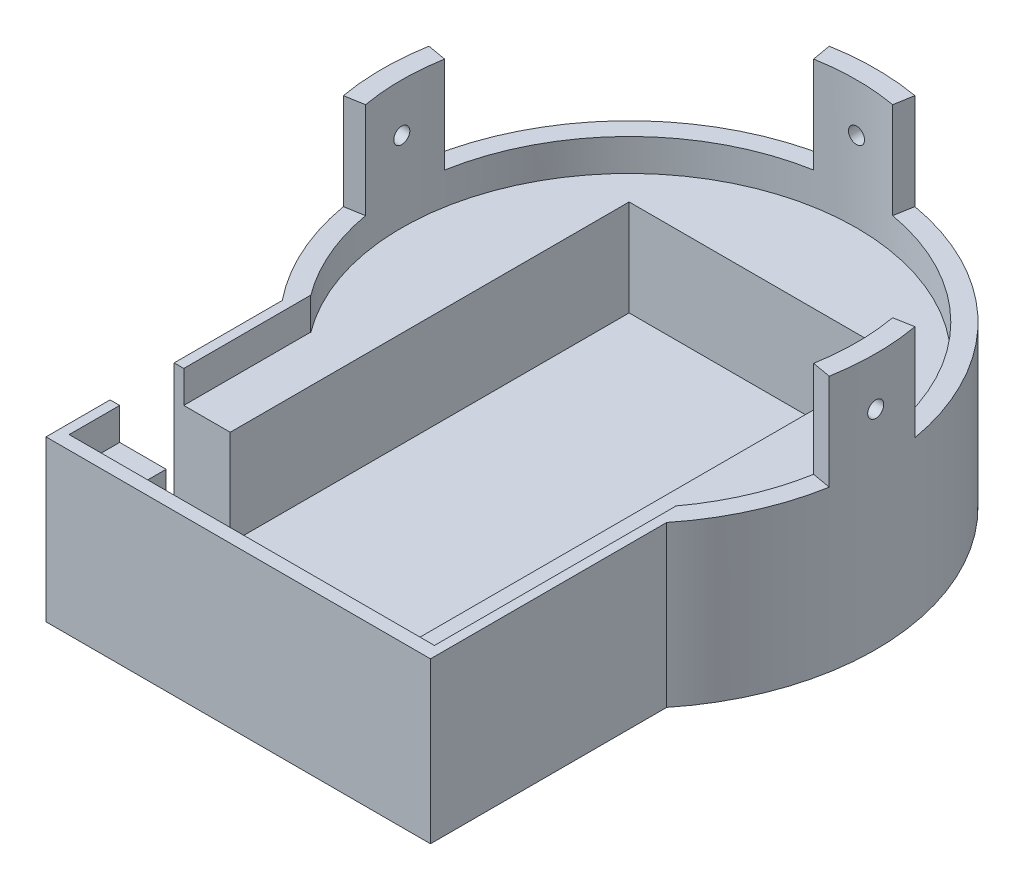
from build123d import *

# Parameters (mm, degrees)
EXTRUDE_1_DEPTH                 = 50
SKETCH_2_W                      = 85
SKETCH_2_H                      = 85
CUT_EXTRUDE_1_DEPTH             = 40
SKETCH_3_R                      = 71
CUT_EXTRUDE_2_DEPTH             = 10
EXTRUDE_2_DEPTH                 = 30
PATTERN_CIRCULAR_1_COUNT        = 4
PATTERN_CIRCULAR_1_COPY_1_DEPTH = 30
PATTERN_CIRCULAR_1_COPY_2_DEPTH = 30
SKETCH_8_R                      = 2.5
CUT_EXTRUDE_3_DEPTH             = 30
PATTERN_CIRCULAR_2_COUNT        = 4
CUT_EXTRUDE_4_DEPTH             = 10
SKETCH_10_W                     = 85
SKETCH_10_H                     = 75.258890594
CUT_EXTRUDE_6_DEPTH             = 30
SKETCH_11_W                     = 114
SKETCH_11_H                     = 4.24
EXTRUDE_3_DEPTH                 = 10
SKETCH_12_W                     = 40
SKETCH_12_H                     = 20
CUT_EXTRUDE_7_DEPTH             = 40


with BuildPart() as part:
    # Эскиз1 → Бобышка-Вытянуть1 (new body)
    with BuildSketch(Plane(origin=(0, 0, 0), x_dir=(1, 0, 0), z_dir=(0, 1, 0))):
        with BuildLine():
            Line((-60, -74.613885), (-60, -48.259714048))
            ThreePointArc((-60, -48.259714048), (0, 77), (60, -48.259714048))
            Line((60, -48.259714048), (60, -74.613885))
            Line((60, -74.613885), (60, -122))
            Line((60, -122), (-60, -122))
            Line((-60, -122), (-60, -74.613885))
        make_face()
    extrude(amount=EXTRUDE_1_DEPTH)

    # Эскиз2 → Вырез-Вытянуть1 (cut)
    with BuildSketch(Plane(origin=(0, 50, 0), x_dir=(1, 0, 0), z_dir=(0, 1, 0))):
        Rectangle(SKETCH_2_W, SKETCH_2_H)
    extrude(amount=-CUT_EXTRUDE_1_DEPTH, mode=Mode.SUBTRACT)

    # Эскиз3 → Вырез-Вытянуть2 (cut)
    with BuildSketch(Plane(origin=(0, 50, 0), x_dir=(1, 0, 0), z_dir=(0, 1, 0))):
        Circle(SKETCH_3_R)
    extrude(amount=-CUT_EXTRUDE_2_DEPTH, mode=Mode.SUBTRACT)

    # Эскиз4 → Бобышка-Вытянуть2 (add)
    with BuildSketch(Plane(origin=(0, 50, 0), x_dir=(1, 0, 0), z_dir=(0, 1, 0))):
        with BuildLine():
            Line((0, 71), (0, 77))
            ThreePointArc((0, 77), (-6.710992192, 76.706991753), (-13.37090968, 75.830196982))
            Line((-13.37090968, 75.830196982), (-12.329020614, 69.921350464))
            ThreePointArc((-12.329020614, 69.921350464), (-6.188057735, 70.729823565), (0, 71))
        make_face()
    extrude_2 = extrude(amount=EXTRUDE_2_DEPTH)

    # Зеркальное отражение1: Бобышка-Вытянуть2 across plane
    add(extrude_2.mirror(Plane(origin=(0, 0, 0), x_dir=(0, 0, 1), z_dir=(1, 0, 0))))

    # Круговой массив1: Бобышка-Вытянуть2 ×4 about axis, 1 skipped
    pattern_circular_1_axis = Axis((0, 0, 0), (0, 1, 0))
    add([extrude_2.rotate(pattern_circular_1_axis, i * 360 / PATTERN_CIRCULAR_1_COUNT) for i in range(1, PATTERN_CIRCULAR_1_COUNT) if i not in (2,)])

    # Круговой массив1 copy 1 sketch → Круговой массив1 copy 1 (add)
    with BuildSketch(Plane.ZX.offset(50)):
        with BuildLine():
            Line((0, -71), (0, -77))
            ThreePointArc((0, -77), (-6.710992192, -76.706991753), (-13.37090968, -75.830196982))
            Line((-13.37090968, -75.830196982), (-12.329020614, -69.921350464))
            ThreePointArc((-12.329020614, -69.921350464), (-6.188057735, -70.729823565), (0, -71))
        make_face()
    extrude(amount=PATTERN_CIRCULAR_1_COPY_1_DEPTH)

    # Круговой массив1 copy 2 sketch → Круговой массив1 copy 2 (add)
    with BuildSketch(Plane(origin=(0, 50, 0), x_dir=(0, 0, -1), z_dir=(0, 1, 0))):
        with BuildLine():
            Line((0, -71), (0, -77))
            ThreePointArc((0, -77), (-6.710992192, -76.706991753), (-13.37090968, -75.830196982))
            Line((-13.37090968, -75.830196982), (-12.329020614, -69.921350464))
            ThreePointArc((-12.329020614, -69.921350464), (-6.188057735, -70.729823565), (0, -71))
        make_face()
    extrude(amount=PATTERN_CIRCULAR_1_COPY_2_DEPTH)

    # Эскиз8 → Вырез-Вытянуть3 (cut)
    with BuildSketch(Plane.XY.offset(-70)):
        with Locations((0, 65)):
            Circle(SKETCH_8_R)
    cut_extrude_3 = extrude(amount=-CUT_EXTRUDE_3_DEPTH, mode=Mode.SUBTRACT)

    # Круговой массив2: Вырез-Вытянуть3 ×4 about axis
    pattern_circular_2_axis = Axis((0, 0, 0), (0, 1, 0))
    for i in range(1, PATTERN_CIRCULAR_2_COUNT):
        add(cut_extrude_3.rotate(pattern_circular_2_axis, i * 360 / PATTERN_CIRCULAR_2_COUNT), mode=Mode.SUBTRACT)

    # Эскиз9 → Вырез-Вытянуть4 (cut)
    with BuildSketch(Plane(origin=(0, 50, 0), x_dir=(1, 0, 0), z_dir=(0, 1, 0))):
        Polygon((-57, -68), (-57, -42.5), (57, -42.5), (57, -124), (-57, -124), align=None)
    extrude(amount=-CUT_EXTRUDE_4_DEPTH, mode=Mode.SUBTRACT)

    # Эскиз10 → Вырез-Вытянуть6 (cut)
    with BuildSketch(Plane(origin=(0, 40, 0), x_dir=(1, 0, 0), z_dir=(0, 1, 0))):
        with Locations((0, -80.129445297)):
            Rectangle(SKETCH_10_W, SKETCH_10_H)
    extrude(amount=-CUT_EXTRUDE_6_DEPTH, mode=Mode.SUBTRACT)

    # Эскиз11 → Бобышка-Вытянуть3 (add)
    with BuildSketch(Plane(origin=(0, 40, 0), x_dir=(1, 0, 0), z_dir=(0, 1, 0))):
        with Locations((0, -119.88)):
            Rectangle(SKETCH_11_W, SKETCH_11_H)
    extrude(amount=EXTRUDE_3_DEPTH)

    # Эскиз12 → Вырез-Вытянуть7 (cut)
    with BuildSketch(Plane(origin=(0, 50, 0), x_dir=(1, 0, 0), z_dir=(0, 1, 0))):
        with Locations((-56.627991745, -92)):
            Rectangle(SKETCH_12_W, SKETCH_12_H)
    extrude(amount=-CUT_EXTRUDE_7_DEPTH, mode=Mode.SUBTRACT)


solid = part.part
